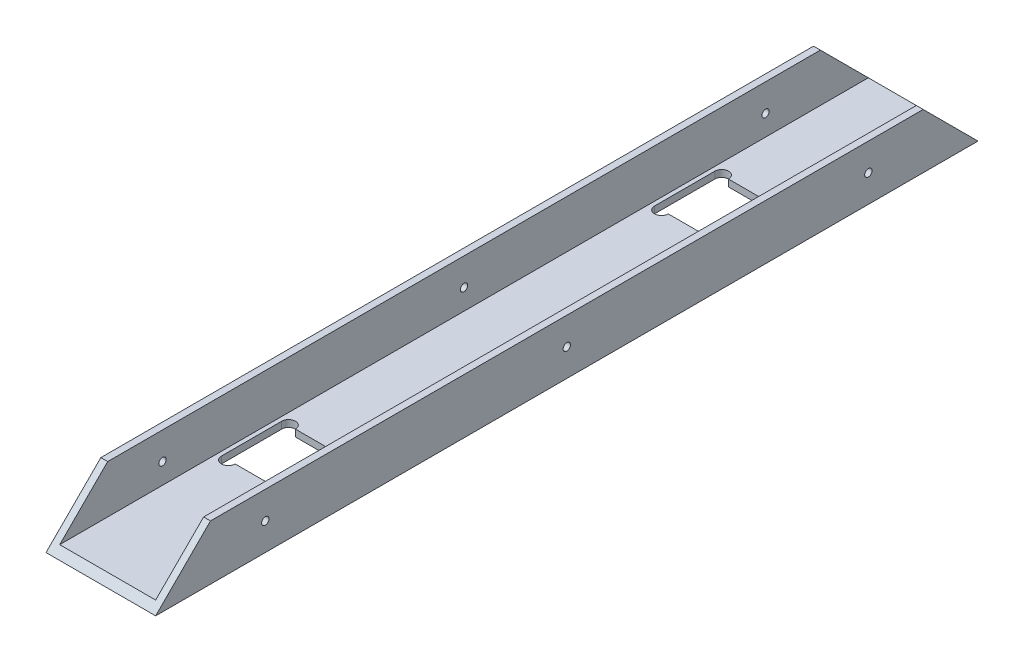
from build123d import *

# Parameters (mm, degrees)
BOSS_EXTRUDE1_DEPTH  = 381
CUT_EXTRUDE1_DEPTH   = 51.8
CUT_EXTRUDE3_DEPTH   = 26.4
M3_CLEARANCE_HOLE1_D = 3.4


with BuildPart() as part:
    # Sketch1 → Boss-Extrude1 (new body)
    with BuildSketch(Plane.XY):
        Polygon((-25.4, 0), (25.4, 0), (25.4, 25.4), (22.225, 25.4), (22.225, 3.175), (-22.225, 3.175), (-22.225, 25.4), (-25.4, 25.4), align=None)
    extrude(amount=BOSS_EXTRUDE1_DEPTH)

    # Sketch2 → Cut-Extrude1 (cut, through all)
    with BuildSketch(Plane(origin=(25.4, 0, 0), x_dir=(0, 0, -1), z_dir=(1, 0, 0))):
        Polygon((-381, 0), (-355.6, 25.4), (-381, 25.4), align=None)
        Polygon((0, 0), (0, 25.4), (-25.4, 25.4), align=None)
    extrude(amount=-CUT_EXTRUDE1_DEPTH, mode=Mode.SUBTRACT)

    # Sketch4 → Cut-Extrude3 (cut, through all)
    with BuildSketch(Plane.XZ):
        with BuildLine():
            Line((-13.97, 276.86), (13.97, 276.86))
            ThreePointArc((13.97, 276.86), (17.145, 273.685), (20.32, 276.86))
            Line((20.32, 276.86), (20.32, 304.8))
            ThreePointArc((20.32, 304.8), (17.145, 307.975), (13.97, 304.8))
            Line((13.97, 304.8), (-13.97, 304.8))
            ThreePointArc((-13.97, 304.8), (-17.145, 307.975), (-20.32, 304.8))
            Line((-20.32, 304.8), (-20.32, 276.86))
            ThreePointArc((-20.32, 276.86), (-17.145, 273.685), (-13.97, 276.86))
        make_face()
        with BuildLine():
            Line((-20.32, 104.14), (-20.32, 76.2))
            ThreePointArc((-20.32, 76.2), (-17.145, 73.025), (-13.97, 76.2))
            Line((-13.97, 76.2), (13.97, 76.2))
            ThreePointArc((13.97, 76.2), (17.145, 73.025), (20.32, 76.2))
            Line((20.32, 76.2), (20.32, 104.14))
            ThreePointArc((20.32, 104.14), (17.145, 107.315), (13.97, 104.14))
            Line((13.97, 104.14), (-13.97, 104.14))
            ThreePointArc((-13.97, 104.14), (-17.145, 107.315), (-20.32, 104.14))
        make_face()
    extrude(amount=-CUT_EXTRUDE3_DEPTH, mode=Mode.SUBTRACT)

    # M3 Clearance Hole1 (through all)
    with Locations(Plane(origin=(-25.4, 12.7, 50.8), x_dir=(0, -1, 0), z_dir=(-1, 0, 0))):
        with Locations((0, 0), (0, 139.7), (0, 279.4)):
            Hole(M3_CLEARANCE_HOLE1_D / 2)


solid = part.part
